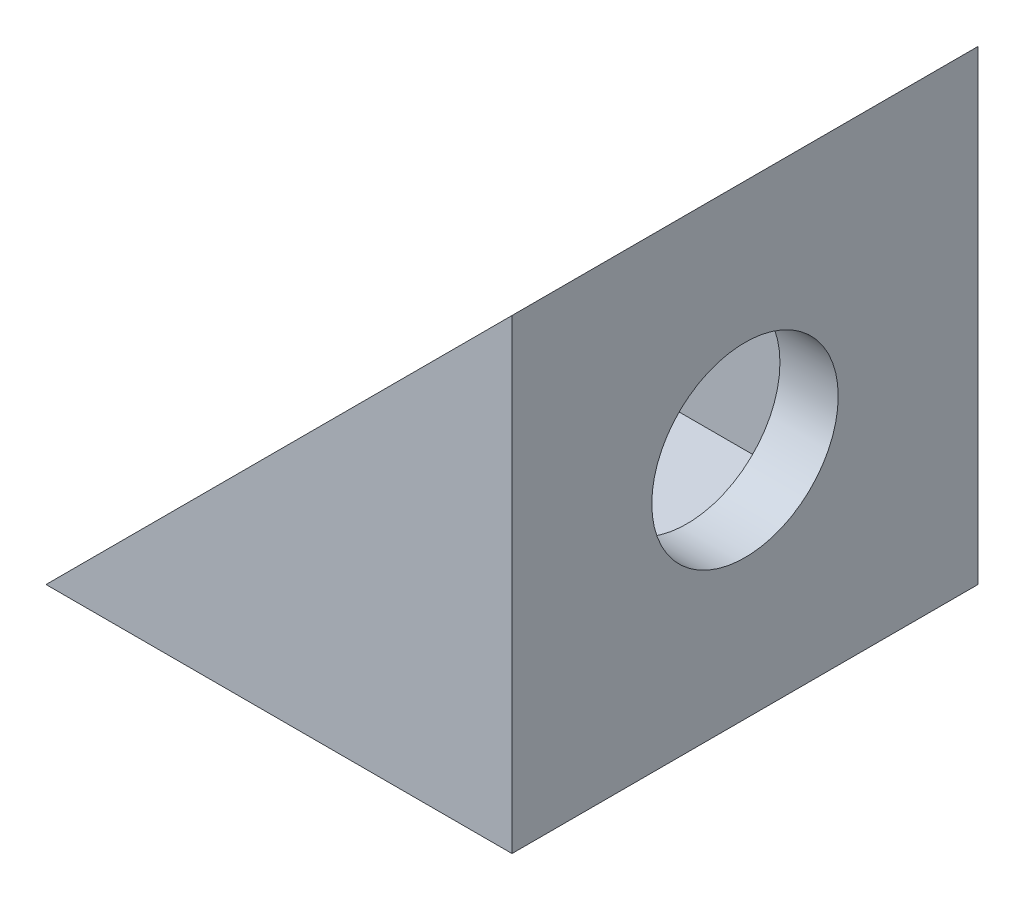
from build123d import *

# Parameters (mm, degrees)
SKETCH1_W               = 20
SKETCH1_H               = 20
BOSS_EXTRUDE1_DEPTH     = 20
CUT_EXTRUDE1_DEPTH      = 31
CUT_EXTRUDE1_DEPTH_BACK = 31
SKETCH3_R               = 4
CUT_EXTRUDE2_DEPTH      = 31
SKETCH4_R               = 4
CUT_EXTRUDE3_DEPTH      = 25.494897428
SKETCH5_W               = 15
SKETCH5_H               = 15
CUT_EXTRUDE5_DEPTH      = 17.5


with BuildPart() as part:
    # Sketch1 → Boss-Extrude1 (new body)
    with BuildSketch(Plane(origin=(0, 0, 0), x_dir=(1, 0, 0), z_dir=(0, 1, 0))):
        Rectangle(SKETCH1_W, SKETCH1_H)
    extrude(amount=BOSS_EXTRUDE1_DEPTH)

    # Sketch2 → Cut-Extrude1 (cut, two sides: drawn at the far end of the back side and taken through both)
    with BuildSketch(Plane.XY.offset(10).offset(-CUT_EXTRUDE1_DEPTH_BACK)):
        Polygon((-10, 0), (10, 20), (-10, 20), align=None)
    extrude(amount=CUT_EXTRUDE1_DEPTH + CUT_EXTRUDE1_DEPTH_BACK, mode=Mode.SUBTRACT)

    # Sketch3 → Cut-Extrude2 (cut, through all)
    with BuildSketch(Plane(origin=(10, 0, 0), x_dir=(0, 0, -1), z_dir=(1, 0, 0))):
        with Locations((0, 10)):
            Circle(SKETCH3_R)
    extrude(amount=-CUT_EXTRUDE2_DEPTH, mode=Mode.SUBTRACT)

    # Sketch4 → Cut-Extrude3 (cut, through all)
    with BuildSketch(Plane.XZ):
        with Locations(Location((0, 0, 0), (0, 0, 270))):
            Circle(SKETCH4_R)
    extrude(amount=-CUT_EXTRUDE3_DEPTH, mode=Mode.SUBTRACT)

    # Sketch5 → Cut-Extrude5 (cut)
    with BuildSketch(Plane(origin=(0, 20, 0), x_dir=(1, 0, 0), z_dir=(0, 1, 0))):
        Rectangle(SKETCH5_W, SKETCH5_H)
    extrude(amount=-CUT_EXTRUDE5_DEPTH, mode=Mode.SUBTRACT)


solid = part.part
